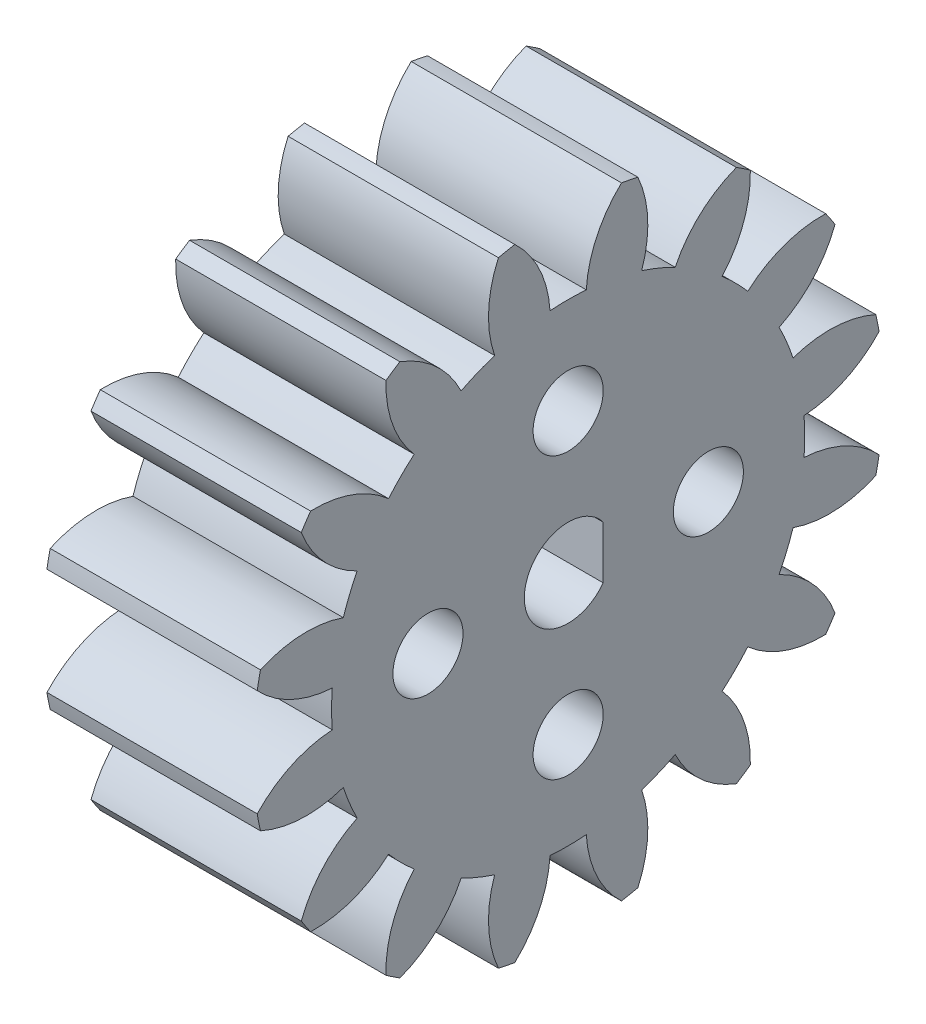
from build123d import *

# Parameters (mm, degrees)
BASPROSKE_W        = 12
BASPROSKE_H        = 18
TOOTHCUT_DEPTH     = 29.142494559
TEETHCUTS_COUNT    = 16
TEETHCUTS_ANGLE    = 337.5
BORSKE_R           = 2
BORE_DEPTH         = 50.0000508
SKETCH1_R          = 2
CUT_EXTRUDE1_DEPTH = 18


with BuildPart() as part:
    # BasProSke → Base-Revolve (revolve)
    with BuildSketch(Plane(origin=(0, 0, 0), x_dir=(1, 0, 0), z_dir=(0, 1, 0)), mode=Mode.PRIVATE) as base_revolve_sk:
        with Locations((6, 9)):
            Rectangle(BASPROSKE_W, BASPROSKE_H)
    revolve(base_revolve_sk.sketch.rotate(Axis((-10, 0, 0), (1, 0, 0)), 180), axis=Axis((-10, 0, 0), (1, 0, 0)))

    # TooCutSke → ToothCut (cut, through all)
    with BuildSketch(Plane(origin=(0, 0, 0), x_dir=(0, 0, -1), z_dir=(1, 0, 0))):
        with BuildLine():
            ThreePointArc((1.03434411, 13.459313997), (0, 13.499), (-1.03434411, 13.459313997))
            ThreePointArc((-1.03434411, 13.459313997), (-1.635143665, 15.806872195), (-3.065655864, 17.762792553))
            ThreePointArc((-3.065655864, 17.762792553), (0, 18.0254), (3.065655864, 17.762792553))
            ThreePointArc((3.065655864, 17.762792553), (1.635143665, 15.806872195), (1.03434411, 13.459313997))
        make_face()
    toothcut = extrude(amount=TOOTHCUT_DEPTH, mode=Mode.SUBTRACT)

    # TeethCuts: ToothCut ×16 about axis
    teethcuts_axis = Axis((-10, 0, 0), (1, 0, 0))
    for i in range(1, TEETHCUTS_COUNT):
        add(toothcut.rotate(teethcuts_axis, i * TEETHCUTS_ANGLE / (TEETHCUTS_COUNT - 1)), mode=Mode.SUBTRACT)

    # BorSke → Bore (cut, symmetric)
    with BuildSketch(Plane(origin=(0, 0, 0), x_dir=(0, 0, -1), z_dir=(1, 0, 0))):
        with Locations(Location((0, 0, 0), (0, 0, 180))):
            Circle(BORSKE_R)
    extrude(amount=BORE_DEPTH, both=True, mode=Mode.SUBTRACT)

    # Sketch1 → Cut-Extrude1 (cut)
    with BuildSketch(Plane(origin=(12, 0, 0), x_dir=(0, 0, -1), z_dir=(1, 0, 0))):
        with Locations((0, 8)):
            Circle(SKETCH1_R)
        with Locations((0, -8)):
            Circle(SKETCH1_R)
        with Locations((8, 0)):
            Circle(SKETCH1_R)
        with Locations((-8, 0)):
            Circle(SKETCH1_R)
        with BuildLine():
            Line((2, 1.5), (2, -1.5))
            ThreePointArc((2, -1.5), (-2.5, 0), (2, 1.5))
        make_face()
    extrude(amount=-CUT_EXTRUDE1_DEPTH, mode=Mode.SUBTRACT)


solid = part.part
